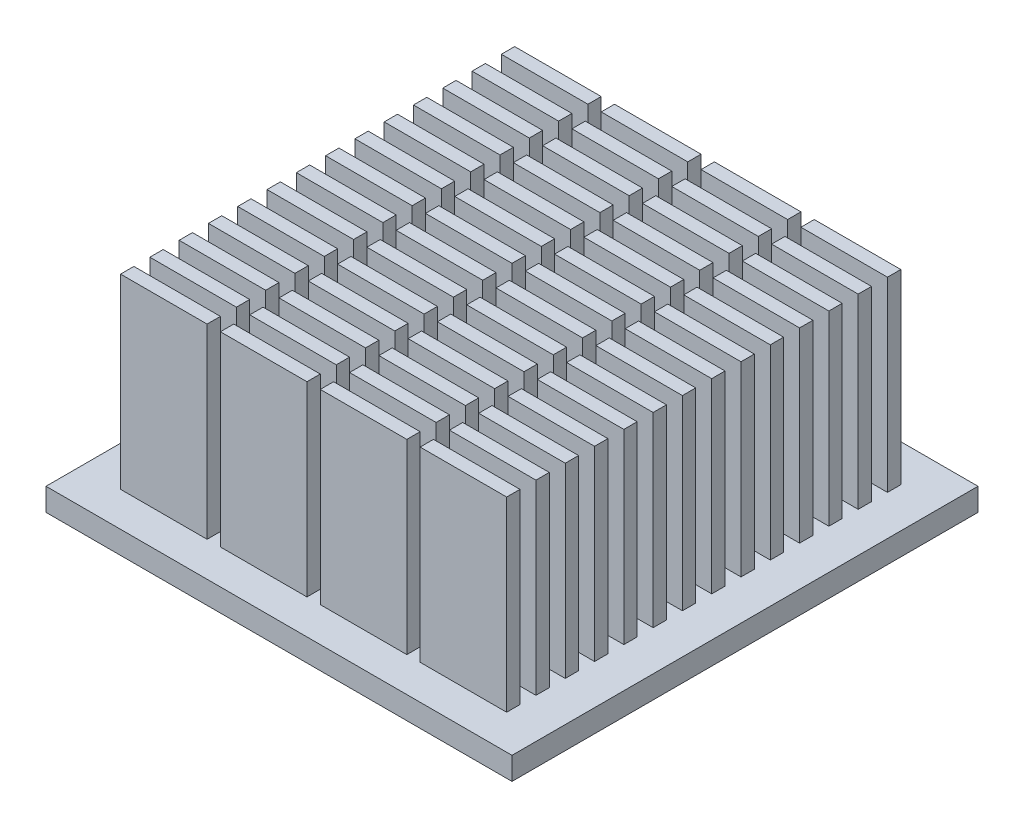
from build123d import *

# Parameters (mm, degrees)
SKETCH1_W           = 35
SKETCH1_H           = 35
BOSS_EXTRUDE1_DEPTH = 1.7
SKETCH2_W           = 6.5
SKETCH2_H           = 1
BOSS_EXTRUDE2_DEPTH = 14


with BuildPart() as part:
    # Sketch1 → Boss-Extrude1 (new body)
    with BuildSketch(Plane(origin=(0, 0, 0), x_dir=(1, 0, 0), z_dir=(0, 1, 0))):
        Rectangle(SKETCH1_W, SKETCH1_H)
    extrude(amount=BOSS_EXTRUDE1_DEPTH)

    # Sketch2 → Boss-Extrude2 (add)
    with BuildSketch(Plane(origin=(0, 1.7, 0), x_dir=(1, 0, 0), z_dir=(0, 1, 0))):
        with Locations((-11.25, -1.2)):
            Rectangle(SKETCH2_W, SKETCH2_H)
        with Locations((-11.25, 1)):
            Rectangle(SKETCH2_W, SKETCH2_H)
        with Locations((-3.75, 1)):
            Rectangle(SKETCH2_W, SKETCH2_H)
        with Locations((3.75, 1)):
            Rectangle(SKETCH2_W, SKETCH2_H)
        with Locations((11.25, 1)):
            Rectangle(SKETCH2_W, SKETCH2_H)
        with Locations((-3.75, -1.2)):
            Rectangle(SKETCH2_W, SKETCH2_H)
        with Locations((3.75, -1.2)):
            Rectangle(SKETCH2_W, SKETCH2_H)
        with Locations((11.25, -1.2)):
            Rectangle(SKETCH2_W, SKETCH2_H)
        with Locations((-11.25, -3.4)):
            Rectangle(SKETCH2_W, SKETCH2_H)
        with Locations((-3.75, -3.4)):
            Rectangle(SKETCH2_W, SKETCH2_H)
        with Locations((3.75, -3.4)):
            Rectangle(SKETCH2_W, SKETCH2_H)
        with Locations((11.25, -3.4)):
            Rectangle(SKETCH2_W, SKETCH2_H)
        with Locations((-11.25, -5.6)):
            Rectangle(SKETCH2_W, SKETCH2_H)
        with Locations((-3.75, -5.6)):
            Rectangle(SKETCH2_W, SKETCH2_H)
        with Locations((3.75, -5.6)):
            Rectangle(SKETCH2_W, SKETCH2_H)
        with Locations((11.25, -5.6)):
            Rectangle(SKETCH2_W, SKETCH2_H)
        with Locations((-11.25, -7.8)):
            Rectangle(SKETCH2_W, SKETCH2_H)
        with Locations((-3.75, -7.8)):
            Rectangle(SKETCH2_W, SKETCH2_H)
        with Locations((3.75, -7.8)):
            Rectangle(SKETCH2_W, SKETCH2_H)
        with Locations((11.25, -7.8)):
            Rectangle(SKETCH2_W, SKETCH2_H)
        with Locations((-11.25, -10)):
            Rectangle(SKETCH2_W, SKETCH2_H)
        with Locations((-3.75, -10)):
            Rectangle(SKETCH2_W, SKETCH2_H)
        with Locations((3.75, -10)):
            Rectangle(SKETCH2_W, SKETCH2_H)
        with Locations((11.25, -10)):
            Rectangle(SKETCH2_W, SKETCH2_H)
        with Locations((-11.25, -12.2)):
            Rectangle(SKETCH2_W, SKETCH2_H)
        with Locations((-3.75, -12.2)):
            Rectangle(SKETCH2_W, SKETCH2_H)
        with Locations((3.75, -12.2)):
            Rectangle(SKETCH2_W, SKETCH2_H)
        with Locations((11.25, -12.2)):
            Rectangle(SKETCH2_W, SKETCH2_H)
        with Locations((-11.25, -14.4)):
            Rectangle(SKETCH2_W, SKETCH2_H)
        with Locations((-3.75, -14.4)):
            Rectangle(SKETCH2_W, SKETCH2_H)
        with Locations((3.75, -14.4)):
            Rectangle(SKETCH2_W, SKETCH2_H)
        with Locations((11.25, -14.4)):
            Rectangle(SKETCH2_W, SKETCH2_H)
        with Locations((-11.25, 3.2)):
            Rectangle(SKETCH2_W, SKETCH2_H)
        with Locations((-3.75, 3.2)):
            Rectangle(SKETCH2_W, SKETCH2_H)
        with Locations((3.75, 3.2)):
            Rectangle(SKETCH2_W, SKETCH2_H)
        with Locations((11.25, 3.2)):
            Rectangle(SKETCH2_W, SKETCH2_H)
        with Locations((-11.25, 5.4)):
            Rectangle(SKETCH2_W, SKETCH2_H)
        with Locations((-3.75, 5.4)):
            Rectangle(SKETCH2_W, SKETCH2_H)
        with Locations((3.75, 5.4)):
            Rectangle(SKETCH2_W, SKETCH2_H)
        with Locations((11.25, 5.4)):
            Rectangle(SKETCH2_W, SKETCH2_H)
        with Locations((-11.25, 7.6)):
            Rectangle(SKETCH2_W, SKETCH2_H)
        with Locations((-3.75, 7.6)):
            Rectangle(SKETCH2_W, SKETCH2_H)
        with Locations((3.75, 7.6)):
            Rectangle(SKETCH2_W, SKETCH2_H)
        with Locations((11.25, 7.6)):
            Rectangle(SKETCH2_W, SKETCH2_H)
        with Locations((-11.25, 9.8)):
            Rectangle(SKETCH2_W, SKETCH2_H)
        with Locations((-3.75, 9.8)):
            Rectangle(SKETCH2_W, SKETCH2_H)
        with Locations((3.75, 9.8)):
            Rectangle(SKETCH2_W, SKETCH2_H)
        with Locations((11.25, 9.8)):
            Rectangle(SKETCH2_W, SKETCH2_H)
        with Locations((-11.25, 12)):
            Rectangle(SKETCH2_W, SKETCH2_H)
        with Locations((-3.75, 12)):
            Rectangle(SKETCH2_W, SKETCH2_H)
        with Locations((3.75, 12)):
            Rectangle(SKETCH2_W, SKETCH2_H)
        with Locations((11.25, 12)):
            Rectangle(SKETCH2_W, SKETCH2_H)
        with Locations((-11.25, 14.2)):
            Rectangle(SKETCH2_W, SKETCH2_H)
        with Locations((-3.75, 14.2)):
            Rectangle(SKETCH2_W, SKETCH2_H)
        with Locations((3.75, 14.2)):
            Rectangle(SKETCH2_W, SKETCH2_H)
        with Locations((11.25, 14.2)):
            Rectangle(SKETCH2_W, SKETCH2_H)
    extrude(amount=BOSS_EXTRUDE2_DEPTH)


solid = part.part
